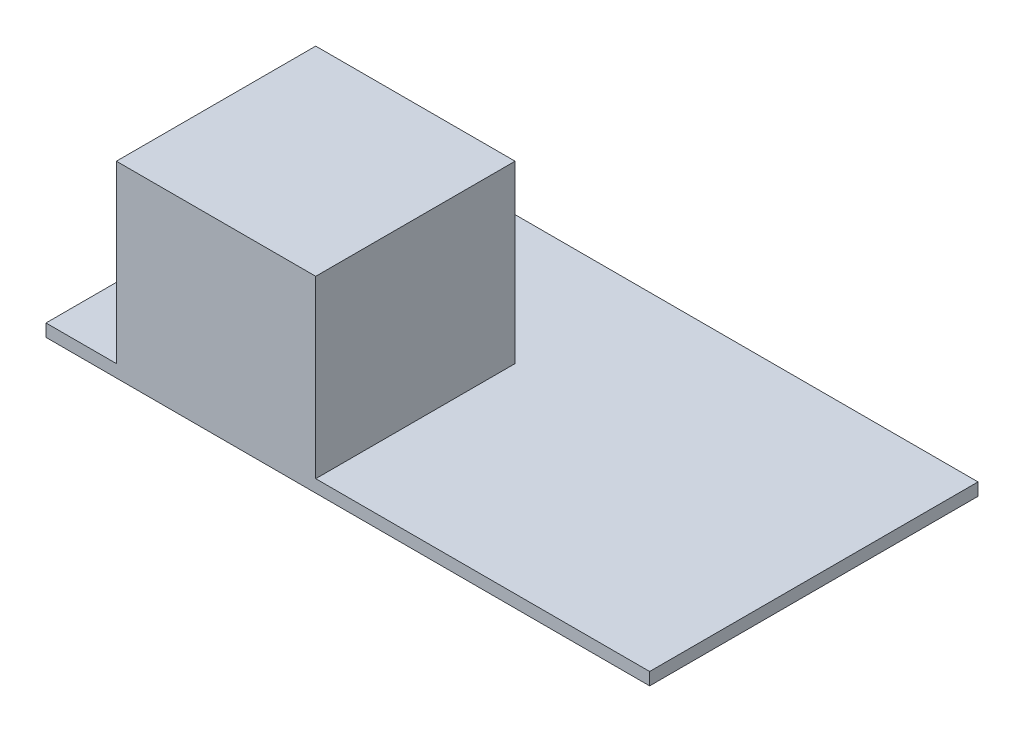
from build123d import *

# Parameters (mm, degrees)
SKETCH1_W           = 77.21
SKETCH1_H           = 42
BOSS_EXTRUDE1_DEPTH = 1.6
SKETCH2_W           = 25.5
SKETCH2_H           = 25.5
BOSS_EXTRUDE2_DEPTH = 22.42


with BuildPart() as part:
    # Sketch1 → Boss-Extrude1 (new body)
    with BuildSketch(Plane(origin=(0, 0, 0), x_dir=(1, 0, 0), z_dir=(0, 1, 0))):
        Rectangle(SKETCH1_W, SKETCH1_H)
    extrude(amount=BOSS_EXTRUDE1_DEPTH)

    # Sketch2 → Boss-Extrude2 (add)
    with BuildSketch(Plane(origin=(0, 1.6, 0), x_dir=(1, 0, 0), z_dir=(0, 1, 0))):
        with Locations((-16.855, -8.25)):
            Rectangle(SKETCH2_W, SKETCH2_H)
    extrude(amount=BOSS_EXTRUDE2_DEPTH)


solid = part.part
